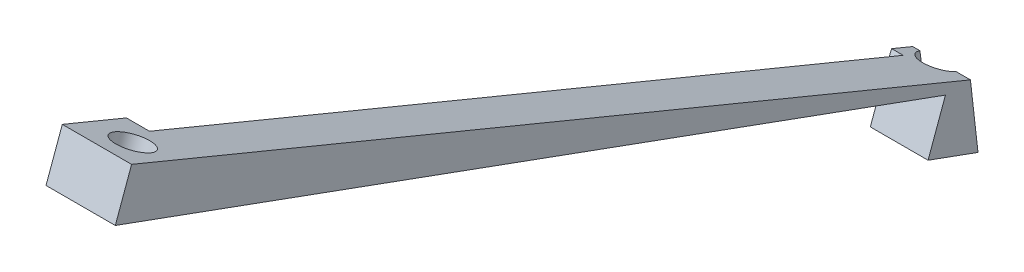
from build123d import *

# Parameters (mm, degrees)
BOSS_EXTRUDE1_DEPTH     = 8
BOSS_EXTRUDE2_DEPTH     = 4
BOSS_EXTRUDE3_DEPTH     = 2
CUT_EXTRUDE1_DEPTH      = 12
CUT_EXTRUDE1_DEPTH_BACK = 84.733662739
SKETCH4_R               = 1.6
SKETCH5_R               = 3.149940151
CUT_EXTRUDE2_DEPTH      = 10
CUT_EXTRUDE3_START      = 9
SKETCH5_2_R             = 3.149940151
CUT_EXTRUDE3_DEPTH      = 9


with BuildPart() as part:
    # Sketch1 → Boss-Extrude1 (new body)
    with BuildSketch(Plane(origin=(0, 0, 0), x_dir=(0, 0, -1), z_dir=(1, 0, 0))):
        Polygon((-74.695832275, 27.991563326), (-71.872967623, 35.747320216), (73.384955245, -24.208131169), (74.695832275, -35.747320216), (66.050660164, -32.600734897), (69.060437425, -24.331439834), align=None)
    extrude(amount=BOSS_EXTRUDE1_DEPTH)

    # Sketch2 → Boss-Extrude2 (add)
    with BuildSketch(Plane.ZY):
        Polygon((74.695832275, 27.991563326), (63.419520826, 23.887321606), (60.770717842, 31.164847991), (71.872967623, 35.747320216), align=None)
    extrude(amount=BOSS_EXTRUDE2_DEPTH)

    # Sketch6 → Boss-Extrude3 (add)
    with BuildSketch(Plane.ZY):
        Polygon((-74.695832275, -35.747320216), (-66.050660164, -32.600734897), (-69.060437425, -24.331439834), (-69.733422771, -22.700955013), (-73.384955245, -24.208131169), (-73.586089176, -25.978642362), align=None)
    extrude(amount=BOSS_EXTRUDE3_DEPTH)

    # Sketch4 → Cut-Extrude1 (cut, two sides: drawn at the far end of the back side and taken through both)
    with BuildSketch(Plane(origin=(0, 0.710394692, -0.258562522), x_dir=(-1, 0, 0), z_dir=(0, -0.9396926207859069, 0.3420201433256729)).offset(-CUT_EXTRUDE1_DEPTH_BACK)):
        with Locations((-2.394217395, -73.485294271)):
            Circle(SKETCH4_R)
        with Locations((-2.394217395, 77.00491749)):
            Circle(SKETCH4_R)
    extrude(amount=CUT_EXTRUDE1_DEPTH + CUT_EXTRUDE1_DEPTH_BACK, mode=Mode.SUBTRACT)

    # Sketch5 → Cut-Extrude2 (cut)
    with BuildSketch(Plane(origin=(0, 5.408857796, -1.968663239), x_dir=(-1, 0, 0), z_dir=(0, -0.9396926207859069, 0.3420201433256729))):
        with Locations((-2.394217395, -73.485294271)):
            Circle(SKETCH5_R)
        with Locations((-2.394217395, 77.514705729)):
            Circle(SKETCH5_R)
    extrude(amount=-CUT_EXTRUDE2_DEPTH, mode=Mode.SUBTRACT)

    # Sketch5_2 → Cut-Extrude3 (cut)
    with BuildSketch(Plane(origin=(0, 5.408857796, -1.968663239), x_dir=(-1, 0, 0), z_dir=(0, -0.9396926207859069, 0.3420201433256729)).offset(CUT_EXTRUDE3_START)):
        with Locations((-2.394217395, -73.485294271)):
            Circle(SKETCH5_2_R)
        with Locations((-2.394217395, 77.514705729)):
            Circle(SKETCH5_2_R)
    extrude(amount=-CUT_EXTRUDE3_DEPTH, mode=Mode.SUBTRACT)


solid = part.part
